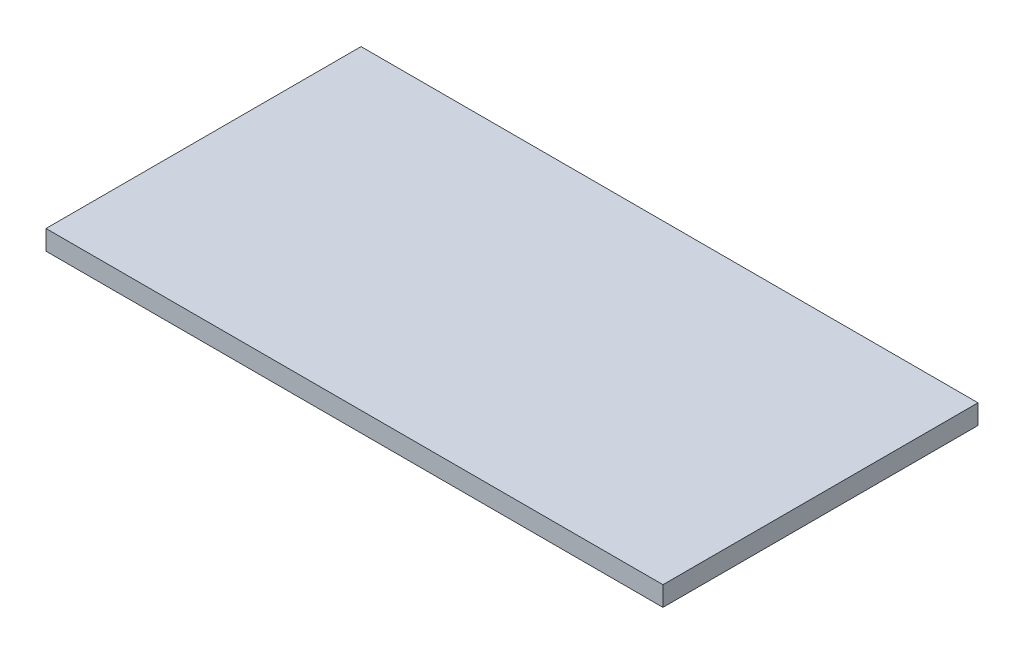
from build123d import *

# Parameters (mm, degrees)
SKETCH1_W           = 564
SKETCH1_H           = 288
BOSS_EXTRUDE1_DEPTH = 18


with BuildPart() as part:
    # Sketch1 → Boss-Extrude1 (new body)
    with BuildSketch(Plane(origin=(0, 0, 0), x_dir=(1, 0, 0), z_dir=(0, 1, 0))):
        Rectangle(SKETCH1_W, SKETCH1_H)
    extrude(amount=BOSS_EXTRUDE1_DEPTH)


solid = part.part
